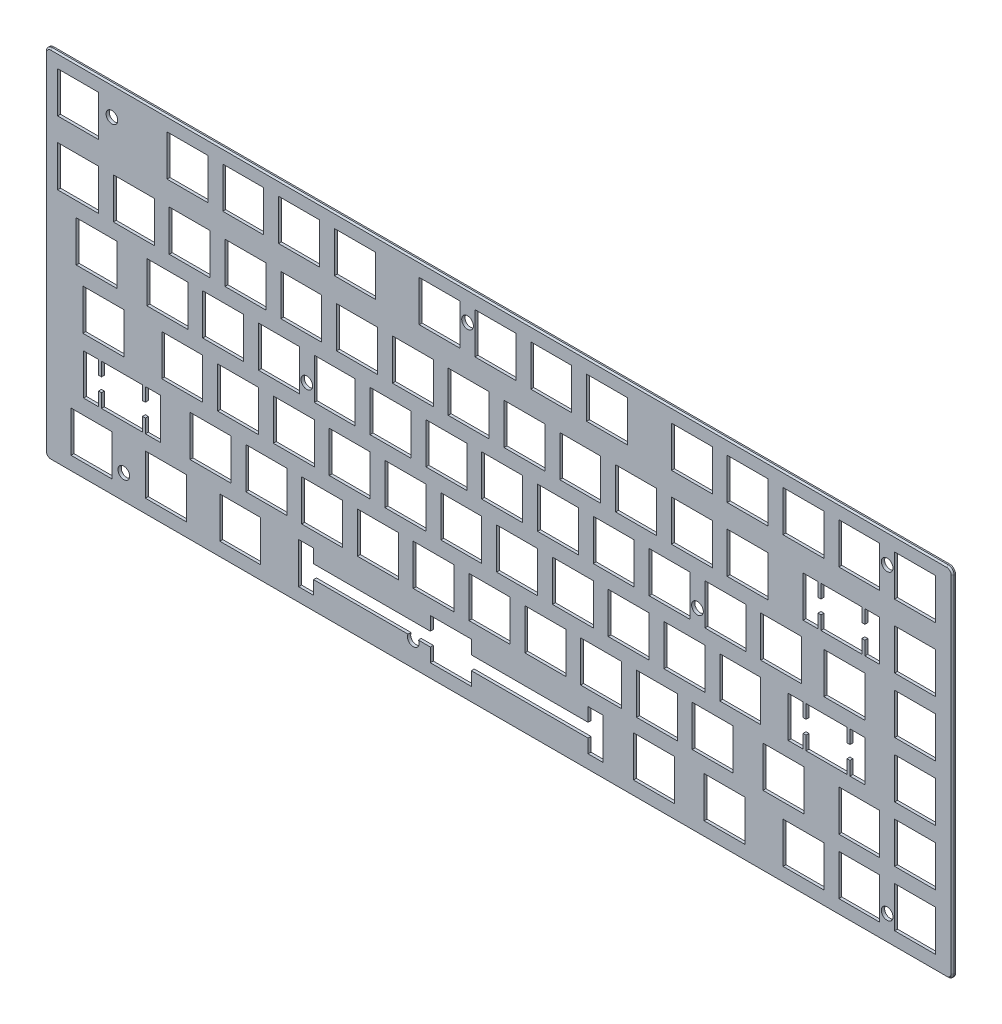
from build123d import *

# Parameters (mm, degrees)
CROQUIS1_W              = 13.97
CROQUIS1_H              = 13.97
SALIENTE_EXTRUIR1_DEPTH = 0.9906
CHAFL_N1_SIZE           = 0.508
TALADRO1_AT_2_COUNT     = 2
TALADRO1_AT_2_PITCH     = 85.194189943
TALADRO1_AT_3_COUNT     = 2
TALADRO1_AT_3_PITCH     = 103.20404775
TALADRO1_AT_4_COUNT     = 2
TALADRO1_AT_4_PITCH     = 156.221357311
TALADRO1_AT_5_COUNT     = 2
TALADRO1_AT_5_PITCH     = 98.806
TALADRO1_AT_6_COUNT     = 2
TALADRO1_AT_6_PITCH     = 280.265952609
TALADRO1_AT_7_COUNT     = 2
TALADRO1_AT_7_PITCH     = 260.604
TALADRO1_AT_8_COUNT     = 2
TALADRO1_AT_8_PITCH     = 204.217421637


with BuildPart() as part:
    # Croquis1 → Saliente-Extruir1 (new body)
    with BuildSketch(Plane.XY):
        with BuildLine():
            Line((-150.876, -60.96), (154.94, -60.96))
            ThreePointArc((154.94, -60.96), (156.376840979, -60.364840979), (156.972, -58.928))
            Line((156.972, -58.928), (156.972, 58.928))
            ThreePointArc((156.972, 58.928), (156.376840979, 60.364840979), (154.94, 60.96))
            Line((154.94, 60.96), (-150.876, 60.96))
            ThreePointArc((-150.876, 60.96), (-152.312840979, 60.364840979), (-152.908, 58.928))
            Line((-152.908, 58.928), (-152.908, -58.928))
            ThreePointArc((-152.908, -58.928), (-152.312840979, -60.364840979), (-150.876, -60.96))
        make_face()
        with Locations((-137.033, -48.895)):
            Rectangle(CROQUIS1_W, CROQUIS1_H, mode=Mode.SUBTRACT)
        with Locations((-111.633, -48.895)):
            Rectangle(CROQUIS1_W, CROQUIS1_H, mode=Mode.SUBTRACT)
        with Locations((-86.233, -48.895)):
            Rectangle(CROQUIS1_W, CROQUIS1_H, mode=Mode.SUBTRACT)
        Polygon((-21.336, -55.88), (-21.336, -51.223333333), (-61.214, -51.223333333), (-61.214, -55.88), (-66.294, -55.88), (-66.294, -41.91), (-61.214, -41.91), (-61.214, -46.566666667), (-21.336, -46.566666667), (-21.336, -41.91), (-7.366, -41.91), (-7.366, -46.566666667), (32.512, -46.566666667), (32.512, -41.91), (37.592, -41.91), (37.592, -55.88), (32.512, -55.88), (32.512, -51.223333333), (-7.366, -51.223333333), (-7.366, -55.88), align=None, mode=Mode.SUBTRACT)
        Polygon((-133.604, -36.83), (-133.604, -32.173333333), (-134.62, -32.173333333), (-134.62, -36.83), (-139.7, -36.83), (-139.7, -22.86), (-134.62, -22.86), (-134.62, -27.516666667), (-133.604, -27.516666667), (-133.604, -22.86), (-119.634, -22.86), (-119.634, -27.516666667), (-118.618, -27.516666667), (-118.618, -22.86), (-113.538, -22.86), (-113.538, -36.83), (-118.618, -36.83), (-118.618, -32.173333333), (-119.634, -32.173333333), (-119.634, -36.83), align=None, mode=Mode.SUBTRACT)
        with Locations((144.145, -48.895)):
            Rectangle(CROQUIS1_W, CROQUIS1_H, mode=Mode.SUBTRACT)
        with Locations((125.095, -48.895)):
            Rectangle(CROQUIS1_W, CROQUIS1_H, mode=Mode.SUBTRACT)
        with Locations((106.045, -48.895)):
            Rectangle(CROQUIS1_W, CROQUIS1_H, mode=Mode.SUBTRACT)
        with Locations((125.095, -29.845)):
            Rectangle(CROQUIS1_W, CROQUIS1_H, mode=Mode.SUBTRACT)
        with Locations((144.145, -29.845)):
            Rectangle(CROQUIS1_W, CROQUIS1_H, mode=Mode.SUBTRACT)
        with Locations((144.145, -10.795)):
            Rectangle(CROQUIS1_W, CROQUIS1_H, mode=Mode.SUBTRACT)
        with Locations((144.145, 8.255)):
            Rectangle(CROQUIS1_W, CROQUIS1_H, mode=Mode.SUBTRACT)
        with Locations((144.145, 27.305)):
            Rectangle(CROQUIS1_W, CROQUIS1_H, mode=Mode.SUBTRACT)
        with Locations((79.121, -48.895)):
            Rectangle(CROQUIS1_W, CROQUIS1_H, mode=Mode.SUBTRACT)
        with Locations((54.991, -48.895)):
            Rectangle(CROQUIS1_W, CROQUIS1_H, mode=Mode.SUBTRACT)
        with Locations((99.187, -29.845)):
            Rectangle(CROQUIS1_W, CROQUIS1_H, mode=Mode.SUBTRACT)
        with Locations((75.057, -29.845)):
            Rectangle(CROQUIS1_W, CROQUIS1_H, mode=Mode.SUBTRACT)
        with Locations((56.007, -29.845)):
            Rectangle(CROQUIS1_W, CROQUIS1_H, mode=Mode.SUBTRACT)
        with Locations((36.957, -29.845)):
            Rectangle(CROQUIS1_W, CROQUIS1_H, mode=Mode.SUBTRACT)
        with Locations((17.907, -29.845)):
            Rectangle(CROQUIS1_W, CROQUIS1_H, mode=Mode.SUBTRACT)
        with Locations((-1.143, -29.845)):
            Rectangle(CROQUIS1_W, CROQUIS1_H, mode=Mode.SUBTRACT)
        with Locations((-20.193, -29.845)):
            Rectangle(CROQUIS1_W, CROQUIS1_H, mode=Mode.SUBTRACT)
        with Locations((-39.243, -29.845)):
            Rectangle(CROQUIS1_W, CROQUIS1_H, mode=Mode.SUBTRACT)
        with Locations((-58.293, -29.845)):
            Rectangle(CROQUIS1_W, CROQUIS1_H, mode=Mode.SUBTRACT)
        with Locations((-77.343, -29.845)):
            Rectangle(CROQUIS1_W, CROQUIS1_H, mode=Mode.SUBTRACT)
        with Locations((-96.393, -29.845)):
            Rectangle(CROQUIS1_W, CROQUIS1_H, mode=Mode.SUBTRACT)
        with Locations((-132.969, -10.795)):
            Rectangle(CROQUIS1_W, CROQUIS1_H, mode=Mode.SUBTRACT)
        with Locations((-86.995, -10.795)):
            Rectangle(CROQUIS1_W, CROQUIS1_H, mode=Mode.SUBTRACT)
        with Locations((-106.045, -10.795)):
            Rectangle(CROQUIS1_W, CROQUIS1_H, mode=Mode.SUBTRACT)
        with Locations((-67.945, -10.795)):
            Rectangle(CROQUIS1_W, CROQUIS1_H, mode=Mode.SUBTRACT)
        with Locations((-48.895, -10.795)):
            Rectangle(CROQUIS1_W, CROQUIS1_H, mode=Mode.SUBTRACT)
        with Locations((-29.845, -10.795)):
            Rectangle(CROQUIS1_W, CROQUIS1_H, mode=Mode.SUBTRACT)
        with Locations((-10.795, -10.795)):
            Rectangle(CROQUIS1_W, CROQUIS1_H, mode=Mode.SUBTRACT)
        with Locations((8.255, -10.795)):
            Rectangle(CROQUIS1_W, CROQUIS1_H, mode=Mode.SUBTRACT)
        with Locations((27.305, -10.795)):
            Rectangle(CROQUIS1_W, CROQUIS1_H, mode=Mode.SUBTRACT)
        with Locations((46.355, -10.795)):
            Rectangle(CROQUIS1_W, CROQUIS1_H, mode=Mode.SUBTRACT)
        with Locations((65.405, -10.795)):
            Rectangle(CROQUIS1_W, CROQUIS1_H, mode=Mode.SUBTRACT)
        with Locations((84.455, -10.795)):
            Rectangle(CROQUIS1_W, CROQUIS1_H, mode=Mode.SUBTRACT)
        Polygon((106.934, -17.78), (106.934, -13.123333333), (105.918, -13.123333333), (105.918, -17.78), (100.838, -17.78), (100.838, -3.81), (105.918, -3.81), (105.918, -8.466666667), (106.934, -8.466666667), (106.934, -3.81), (120.904, -3.81), (120.904, -8.466666667), (121.92, -8.466666667), (121.92, -3.81), (127, -3.81), (127, -17.78), (121.92, -17.78), (121.92, -13.123333333), (120.904, -13.123333333), (120.904, -17.78), align=None, mode=Mode.SUBTRACT)
        with Locations((-111.125, 8.255)):
            Rectangle(CROQUIS1_W, CROQUIS1_H, mode=Mode.SUBTRACT)
        with Locations((-92.075, 8.255)):
            Rectangle(CROQUIS1_W, CROQUIS1_H, mode=Mode.SUBTRACT)
        with Locations((-73.025, 8.255)):
            Rectangle(CROQUIS1_W, CROQUIS1_H, mode=Mode.SUBTRACT)
        with Locations((-53.975, 8.255)):
            Rectangle(CROQUIS1_W, CROQUIS1_H, mode=Mode.SUBTRACT)
        with Locations((-34.925, 8.255)):
            Rectangle(CROQUIS1_W, CROQUIS1_H, mode=Mode.SUBTRACT)
        with Locations((-15.875, 8.255)):
            Rectangle(CROQUIS1_W, CROQUIS1_H, mode=Mode.SUBTRACT)
        with Locations((3.175, 8.255)):
            Rectangle(CROQUIS1_W, CROQUIS1_H, mode=Mode.SUBTRACT)
        with Locations((22.225, 8.255)):
            Rectangle(CROQUIS1_W, CROQUIS1_H, mode=Mode.SUBTRACT)
        with Locations((41.275, 8.255)):
            Rectangle(CROQUIS1_W, CROQUIS1_H, mode=Mode.SUBTRACT)
        with Locations((60.325, 8.255)):
            Rectangle(CROQUIS1_W, CROQUIS1_H, mode=Mode.SUBTRACT)
        with Locations((79.375, 8.255)):
            Rectangle(CROQUIS1_W, CROQUIS1_H, mode=Mode.SUBTRACT)
        with Locations((98.425, 8.255)):
            Rectangle(CROQUIS1_W, CROQUIS1_H, mode=Mode.SUBTRACT)
        with Locations((120.015, 8.255)):
            Rectangle(CROQUIS1_W, CROQUIS1_H, mode=Mode.SUBTRACT)
        Polygon((112.014, 20.32), (112.014, 24.976666667), (110.998, 24.976666667), (110.998, 20.32), (105.918, 20.32), (105.918, 34.29), (110.998, 34.29), (110.998, 29.633333333), (112.014, 29.633333333), (112.014, 34.29), (125.984, 34.29), (125.984, 29.633333333), (127, 29.633333333), (127, 34.29), (132.08, 34.29), (132.08, 20.32), (127, 20.32), (127, 24.976666667), (125.984, 24.976666667), (125.984, 20.32), align=None, mode=Mode.SUBTRACT)
        with Locations((-135.255, 8.255)):
            Rectangle(CROQUIS1_W, CROQUIS1_H, mode=Mode.SUBTRACT)
        with Locations((144.145, 49.149)):
            Rectangle(CROQUIS1_W, CROQUIS1_H, mode=Mode.SUBTRACT)
        with Locations((125.095, 49.149)):
            Rectangle(CROQUIS1_W, CROQUIS1_H, mode=Mode.SUBTRACT)
        with Locations((106.045, 49.149)):
            Rectangle(CROQUIS1_W, CROQUIS1_H, mode=Mode.SUBTRACT)
        with Locations((86.995, 49.149)):
            Rectangle(CROQUIS1_W, CROQUIS1_H, mode=Mode.SUBTRACT)
        with Locations((67.945, 49.149)):
            Rectangle(CROQUIS1_W, CROQUIS1_H, mode=Mode.SUBTRACT)
        with Locations((67.945, 27.305)):
            Rectangle(CROQUIS1_W, CROQUIS1_H, mode=Mode.SUBTRACT)
        with Locations((48.895, 27.305)):
            Rectangle(CROQUIS1_W, CROQUIS1_H, mode=Mode.SUBTRACT)
        with Locations((29.845, 27.305)):
            Rectangle(CROQUIS1_W, CROQUIS1_H, mode=Mode.SUBTRACT)
        with Locations((10.795, 27.305)):
            Rectangle(CROQUIS1_W, CROQUIS1_H, mode=Mode.SUBTRACT)
        with Locations((-8.255, 27.305)):
            Rectangle(CROQUIS1_W, CROQUIS1_H, mode=Mode.SUBTRACT)
        with Locations((-27.305, 27.305)):
            Rectangle(CROQUIS1_W, CROQUIS1_H, mode=Mode.SUBTRACT)
        with Locations((-46.355, 27.305)):
            Rectangle(CROQUIS1_W, CROQUIS1_H, mode=Mode.SUBTRACT)
        with Locations((-65.405, 27.305)):
            Rectangle(CROQUIS1_W, CROQUIS1_H, mode=Mode.SUBTRACT)
        with Locations((-84.455, 27.305)):
            Rectangle(CROQUIS1_W, CROQUIS1_H, mode=Mode.SUBTRACT)
        with Locations((-103.505, 27.305)):
            Rectangle(CROQUIS1_W, CROQUIS1_H, mode=Mode.SUBTRACT)
        with Locations((-122.555, 27.305)):
            Rectangle(CROQUIS1_W, CROQUIS1_H, mode=Mode.SUBTRACT)
        with Locations((-141.605, 27.305)):
            Rectangle(CROQUIS1_W, CROQUIS1_H, mode=Mode.SUBTRACT)
        with Locations((86.995, 27.305)):
            Rectangle(CROQUIS1_W, CROQUIS1_H, mode=Mode.SUBTRACT)
        with Locations((-18.161, 49.149)):
            Rectangle(CROQUIS1_W, CROQUIS1_H, mode=Mode.SUBTRACT)
        with Locations((0.889, 49.149)):
            Rectangle(CROQUIS1_W, CROQUIS1_H, mode=Mode.SUBTRACT)
        with Locations((19.939, 49.149)):
            Rectangle(CROQUIS1_W, CROQUIS1_H, mode=Mode.SUBTRACT)
        with Locations((38.989, 49.149)):
            Rectangle(CROQUIS1_W, CROQUIS1_H, mode=Mode.SUBTRACT)
        with Locations((-104.267, 49.149)):
            Rectangle(CROQUIS1_W, CROQUIS1_H, mode=Mode.SUBTRACT)
        with Locations((-85.217, 49.149)):
            Rectangle(CROQUIS1_W, CROQUIS1_H, mode=Mode.SUBTRACT)
        with Locations((-66.167, 49.149)):
            Rectangle(CROQUIS1_W, CROQUIS1_H, mode=Mode.SUBTRACT)
        with Locations((-47.117, 49.149)):
            Rectangle(CROQUIS1_W, CROQUIS1_H, mode=Mode.SUBTRACT)
        with Locations((-141.605, 49.149)):
            Rectangle(CROQUIS1_W, CROQUIS1_H, mode=Mode.SUBTRACT)
    extrude(amount=SALIENTE_EXTRUIR1_DEPTH)

    # Chaflán1
    chafl_n1_edges = [part.edges().sort_by_distance(p)[0] for p in [
        (156.376840979, -60.364840979, 0.9906),
        (156.972, 0, 0.9906),
        (156.376840979, 60.364840979, 0.9906),
        (2.032, 60.96, 0.9906),
        (-152.312840979, 60.364840979, 0.9906),
        (-152.908, 0, 0.9906),
        (-152.312840979, -60.364840979, 0.9906),
        (2.032, -60.96, 0.9906),
    ]]
    chamfer(chafl_n1_edges, length=CHAFL_N1_SIZE)

    # Croquis4 → Taladro1 (revolve, cut)
    with BuildSketch(Plane(origin=(-125.984, -52.07, 0.9906), x_dir=(0, -1, 0), z_dir=(1, 0, 0))):
        Polygon((0, 0), (0, 0.9906), (1.0033, 0.9906), (1.0033, 7.524354024), (1.9939, 0), align=None)
    taladro1 = revolve(axis=Axis((-125.984, -52.07, 7.435914094), (0, 0, -1)), mode=Mode.SUBTRACT)

    # Taladro1 at 2: Taladro1 ×2
    with Locations(*[Vector(0.733430297, 0.679764665, 0) * (i * TALADRO1_AT_2_PITCH) for i in range(1, TALADRO1_AT_2_COUNT)]):
        add(taladro1, mode=Mode.SUBTRACT)

    # Taladro1 at 3: Taladro1 ×2
    with Locations(*[Vector(-0.0393783, 0.999224374, 0) * (i * TALADRO1_AT_3_PITCH) for i in range(1, TALADRO1_AT_3_COUNT)]):
        add(taladro1, mode=Mode.SUBTRACT)

    # Taladro1 at 4: Taladro1 ×2
    with Locations(*[Vector(0.751164898, 0.660114608, 0) * (i * TALADRO1_AT_4_PITCH) for i in range(1, TALADRO1_AT_4_COUNT)]):
        add(taladro1, mode=Mode.SUBTRACT)

    # Taladro1 at 5: Taladro1 ×2
    with Locations(*[(i * TALADRO1_AT_5_PITCH, 0, 0) for i in range(1, TALADRO1_AT_5_COUNT)]):
        add(taladro1, mode=Mode.SUBTRACT)

    # Taladro1 at 6: Taladro1 ×2
    with Locations(*[Vector(0.929845376, 0.367950509, 0) * (i * TALADRO1_AT_6_PITCH) for i in range(1, TALADRO1_AT_6_COUNT)]):
        add(taladro1, mode=Mode.SUBTRACT)

    # Taladro1 at 7: Taladro1 ×2
    with Locations(*[(i * TALADRO1_AT_7_PITCH, 0, 0) for i in range(1, TALADRO1_AT_7_COUNT)]):
        add(taladro1, mode=Mode.SUBTRACT)

    # Taladro1 at 8: Taladro1 ×2
    with Locations(*[Vector(0.958948548, 0.283580115, 0) * (i * TALADRO1_AT_8_PITCH) for i in range(1, TALADRO1_AT_8_COUNT)]):
        add(taladro1, mode=Mode.SUBTRACT)


solid = part.part
